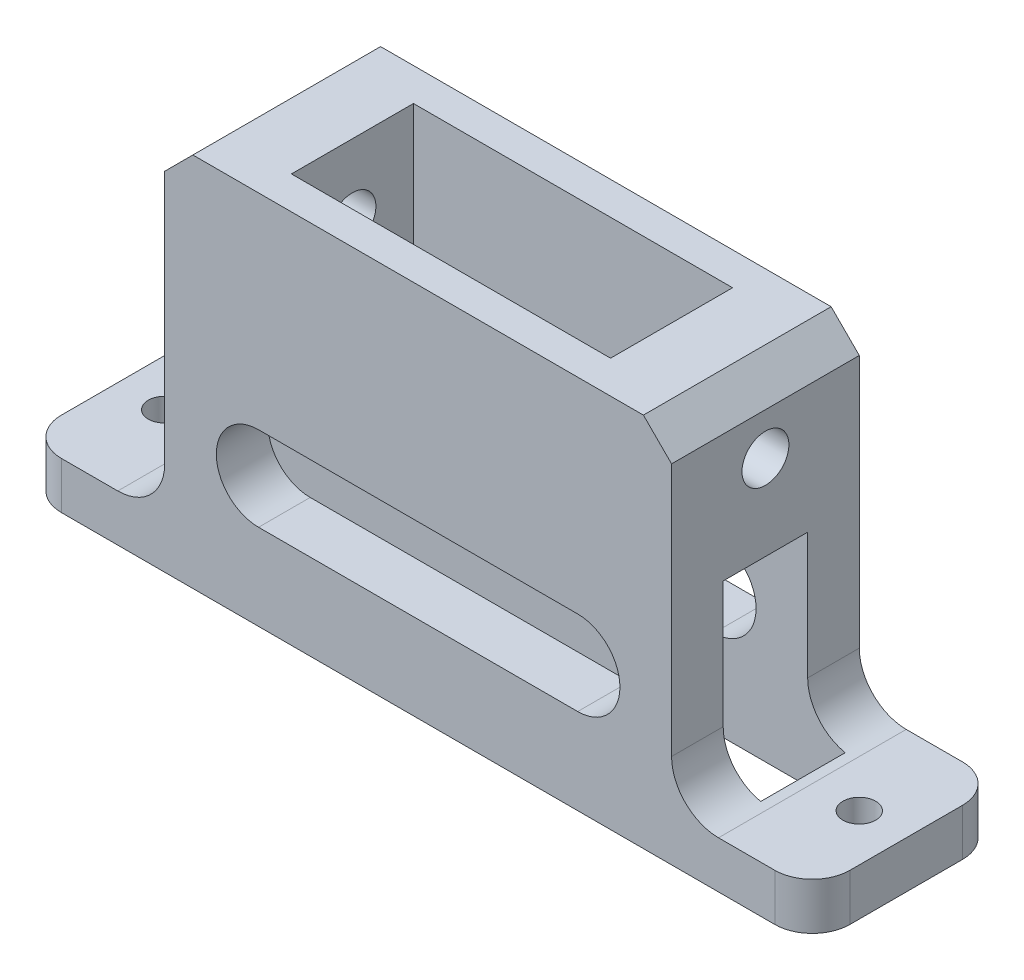
from build123d import *

# Parameters (mm, degrees)
SKETCH1_W           = 54
SKETCH1_H           = 20
BOSS_EXTRUDE1_DEPTH = 40
SKETCH4_W           = 15
SKETCH4_H           = 20
BOSS_EXTRUDE2_DEPTH = 5
FILLET1_R           = 5
SKETCH6_W           = 34
SKETCH6_H           = 13
CUT_EXTRUDE3_DEPTH  = 26.35
CUT_EXTRUDE4_DEPTH  = 21
SKETCH3_R           = 2.5
CUT_EXTRUDE2_DEPTH  = 70
CUT_EXTRUDE5_DEPTH  = 9
SKETCH9_R           = 1.75
CUT_EXTRUDE6_DEPTH  = 6
FILLET2_R           = 4
CHAMFER1_SIZE       = 3


with BuildPart() as part:
    # Sketch1 → Boss-Extrude1 (new body)
    with BuildSketch(Plane(origin=(0, 0, 0), x_dir=(1, 0, 0), z_dir=(0, 1, 0))):
        Rectangle(SKETCH1_W, SKETCH1_H)
    extrude(amount=BOSS_EXTRUDE1_DEPTH)

    # Sketch4 → Boss-Extrude2 (add)
    with BuildSketch(Plane.XZ):
        with Locations((-34.5, 0)):
            Rectangle(SKETCH4_W, SKETCH4_H)
        with Locations((34.5, 0)):
            Rectangle(SKETCH4_W, SKETCH4_H)
    extrude(amount=-BOSS_EXTRUDE2_DEPTH)

    # Fillet1
    fillet1_edges = [part.edges().sort_by_distance(p)[0] for p in [
        (-27, 5, 0),
        (27, 5, 0),
    ]]
    fillet(fillet1_edges, radius=FILLET1_R)

    # Sketch6 → Cut-Extrude3 (cut)
    with BuildSketch(Plane.XZ.offset(-40)):
        Rectangle(SKETCH6_W, SKETCH6_H)
    extrude(amount=CUT_EXTRUDE3_DEPTH, mode=Mode.SUBTRACT)

    # Sketch7 → Cut-Extrude4 (cut, through all)
    with BuildSketch(Plane.XY.offset(10)):
        with BuildLine():
            Line((-17, 18.15), (17, 18.15))
            ThreePointArc((17, 18.15), (21.5, 13.65), (17, 9.15))
            Line((17, 9.15), (-17, 9.15))
            ThreePointArc((-17, 9.15), (-21.5, 13.65), (-17, 18.15))
        make_face()
    extrude(amount=-CUT_EXTRUDE4_DEPTH, mode=Mode.SUBTRACT)

    # Sketch3 → Cut-Extrude2 (cut, through all)
    with BuildSketch(Plane.ZY.offset(27)):
        with Locations((0, 32.52)):
            Circle(SKETCH3_R)
    extrude(amount=-CUT_EXTRUDE2_DEPTH, mode=Mode.SUBTRACT)

    # Sketch8 → Cut-Extrude5 (cut)
    with BuildSketch(Plane(origin=(0, 0, -4.5), x_dir=(-1, 0, 0), z_dir=(0, 0, -1))):
        with BuildLine():
            Line((-17, 27.65), (17, 27.65))
            ThreePointArc((17, 27.65), (26.899494937, 23.549494937), (31, 13.65))
            Line((31, 13.65), (31, 0))
            Line((31, 0), (-31, 0))
            Line((-31, 0), (-31, 13.65))
            ThreePointArc((-31, 13.65), (-26.899494937, 23.549494937), (-17, 27.65))
        make_face()
    extrude(amount=-CUT_EXTRUDE5_DEPTH, mode=Mode.SUBTRACT)

    # Sketch9 → Cut-Extrude6 (cut, through all)
    with BuildSketch(Plane(origin=(0, 5, 0), x_dir=(1, 0, 0), z_dir=(0, 1, 0))):
        with Locations((-37, 0)):
            Circle(SKETCH9_R)
        with Locations((37, 0)):
            Circle(SKETCH9_R)
    extrude(amount=-CUT_EXTRUDE6_DEPTH, mode=Mode.SUBTRACT)

    # Fillet2
    fillet2_edges = [part.edges().sort_by_distance(p)[0] for p in [
        (-42, 2.5, -10),
        (-42, 2.5, 10),
        (42, 2.5, 10),
        (42, 2.5, -10),
    ]]
    fillet(fillet2_edges, radius=FILLET2_R)

    # Chamfer1
    chamfer1_edges = [part.edges().sort_by_distance(p)[0] for p in [
        (-27, 40, 0),
        (27, 40, 0),
    ]]
    chamfer(chamfer1_edges, length=CHAMFER1_SIZE)


solid = part.part
